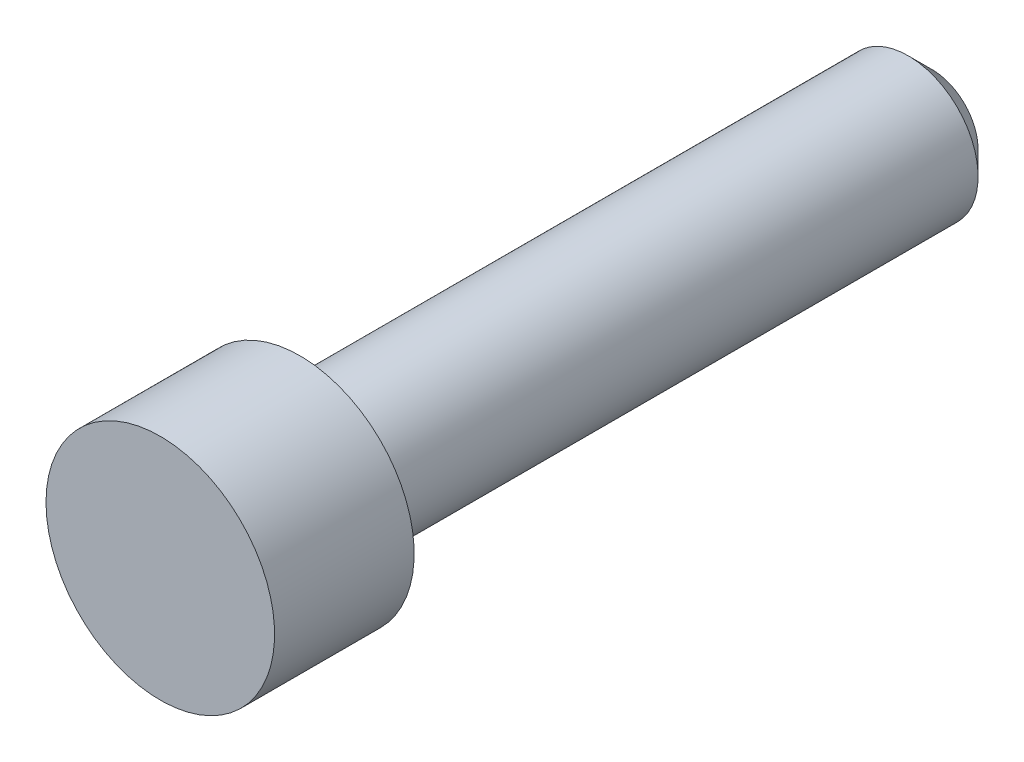
from build123d import *


with BuildPart() as part:
    # Sketch2 → Revolve1 (revolve)
    with BuildSketch(Plane(origin=(0, 0, 0), x_dir=(0, 0, -1), z_dir=(1, 0, 0))):
        Polygon((9.6901, 1.1572875), (9.0947875, 1.7526), (-6.1849, 1.7526), (-6.1849, 2.8702), (-9.6901, 2.8702), (-9.6901, 0), (9.6901, 0), align=None)
    revolve(axis=Axis((0, 0, -9.6901), (0, 0, 1)))


solid = part.part
